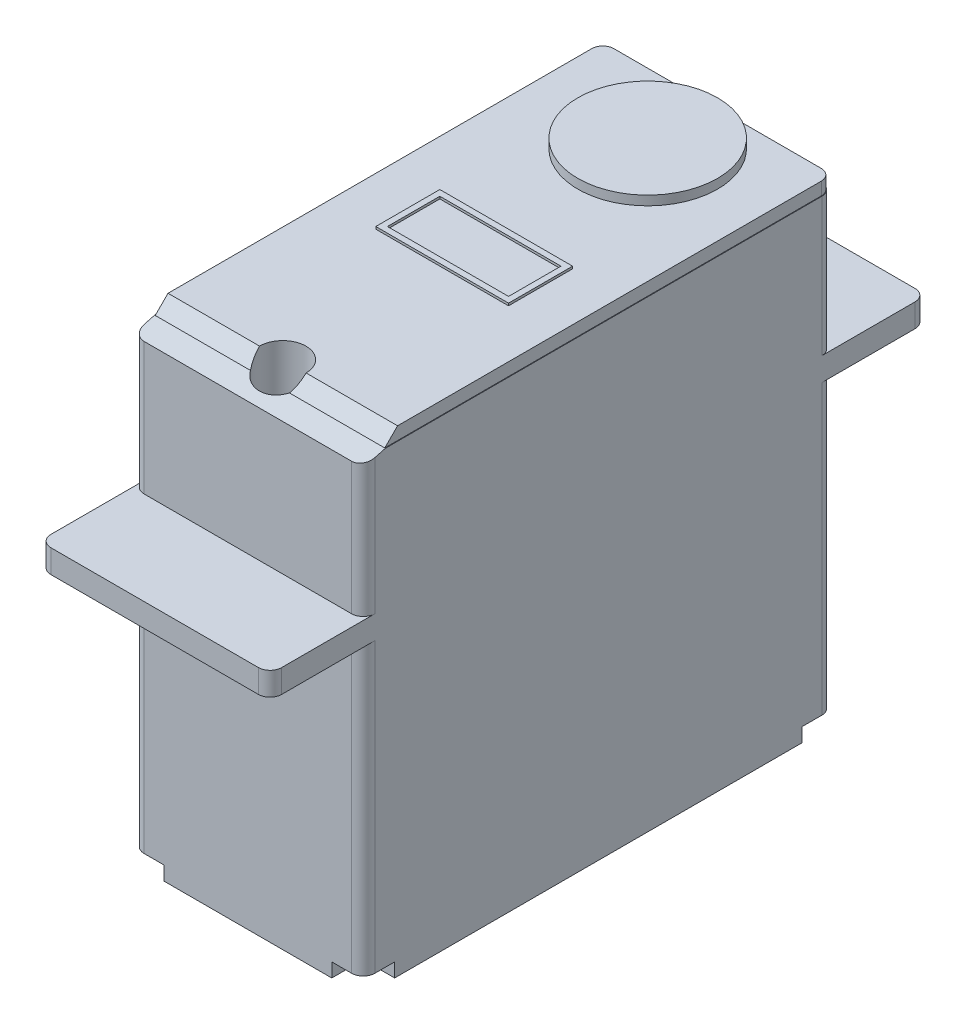
from build123d import *

# Parameters (mm, degrees)
ESQUISSE1_W                                   = 40.386
ESQUISSE1_H                                   = 40.894
BOSS_EXTRU_1_DEPTH                            = 9.906
ESQUISSE3_W                                   = 8.001
ESQUISSE3_H                                   = 2
BOSS_EXTRU_2_DEPTH                            = 19.812
ESQUISSE6_R                                   = 2
ENL_V_MAT_EXTRU_1_DEPTH                       = 13.954000064
ENL_V_MAT_EXTRU_1_DEPTH_BACK                  = 28.939999936
ESQUISSE5_R                                   = 6
BOSS_EXTRU_3_DEPTH                            = 0.8
CONG_2_R                                      = 1
ENL_V_MAT_EXTRU_2_DEPTH                       = 1.1
ENL_V_MAT_EXTRU_3_DEPTH                       = 1
ENL_V_MAT_EXTRU_3_DEPTH_BACK                  = 20.812
ESQUISSE9_W                                   = 11.4
ESQUISSE9_H                                   = 5.5
ESQUISSE9_W_2                                 = 10.4
ESQUISSE9_H_2                                 = 4.5
EXTRU_MINCE1_DEPTH                            = 0.2
ENL_V_MAT_EXTRU_4_DEPTH                       = 1
ENL_V_MAT_EXTRU_4_DEPTH_BACK                  = 1.2
TROU_POUR_TARAUDAGE_POUR_TROU_TARAUD_M1_D     = 0.95
TROU_POUR_TARAUDAGE_POUR_TROU_TARAUD_M1_DEPTH = 4.714591206
TROU_POUR_TARAUDAGE_POUR_TROU_TARAUD_M1_TIP   = 0.285408794
ESQUISSE16_W                                  = 3.6
ESQUISSE16_H                                  = 1.3
ENL_V_MAT_EXTRU_5_DEPTH                       = 5
ESQUISSE17_R                                  = 0.625
BOSS_EXTRU_5_DEPTH                            = 10
BOSS_EXTRU_5_2_DEPTH                          = 10
BOSS_EXTRU_5_3_DEPTH                          = 10


with BuildPart() as part:
    # Esquisse1 → Boss.-Extru.1 (new body, symmetric)
    with BuildSketch(Plane(origin=(0, 0, 0), x_dir=(0, 0, -1), z_dir=(1, 0, 0))):
        Rectangle(ESQUISSE1_W, ESQUISSE1_H)
    extrude(amount=BOSS_EXTRU_1_DEPTH, both=True)

    # Esquisse3 → Boss.-Extru.2 (add)
    with BuildSketch(Plane(origin=(9.906, 0, 0), x_dir=(0, 0, -1), z_dir=(1, 0, 0))):
        with Locations((-24.1935, 6.492999936)):
            Rectangle(ESQUISSE3_W, ESQUISSE3_H)
        with Locations((24.1935, 6.492999936)):
            Rectangle(ESQUISSE3_W, ESQUISSE3_H)
    extrude(amount=-BOSS_EXTRU_2_DEPTH)

    # Esquisse6 → Enlèv. mat.-Extru.1 (cut, two sides)
    with BuildSketch(Plane(origin=(0, 7.492999936, 0), x_dir=(1, 0, 0), z_dir=(0, 1, 0))) as enl_v_mat_extru_1_sk:
        with Locations((0, 17.2)):
            Circle(ESQUISSE6_R)
        with Locations((0, -17.2)):
            Circle(ESQUISSE6_R)
    extrude(amount=ENL_V_MAT_EXTRU_1_DEPTH, mode=Mode.SUBTRACT)
    extrude(enl_v_mat_extru_1_sk.sketch, amount=-ENL_V_MAT_EXTRU_1_DEPTH_BACK, mode=Mode.SUBTRACT)

    # Esquisse5 → Boss.-Extru.3 (add)
    with BuildSketch(Plane(origin=(0, 20.447, 0), x_dir=(1, 0, 0), z_dir=(0, 1, 0))):
        with Locations((0, 14.143)):
            Circle(ESQUISSE5_R)
    extrude(amount=BOSS_EXTRU_3_DEPTH)

    # Congé2
    cong_2_edges = [part.edges().sort_by_distance(p)[0] for p in [
        (9.906, -7.477000032, -20.193),
        (-9.906, 13.969999968, -20.193),
        (9.906, 13.969999968, -20.193),
        (-9.906, -7.477000032, 20.193),
        (9.906, -7.477000032, 20.193),
        (9.906, 6.492999936, 28.194),
        (-9.906, 6.492999936, 28.194),
        (9.906, 6.492999936, -28.194),
        (-9.906, 6.492999936, -28.194),
        (9.906, 13.969999968, 20.193),
        (-9.906, -7.477000032, -20.193),
        (-9.906, 13.969999968, 20.193),
    ]]
    fillet(cong_2_edges, radius=CONG_2_R)

    # Esquisse7 → Enlèv. mat.-Extru.2 (cut)
    with BuildSketch(Plane(origin=(0, 20.447, 0), x_dir=(1, 0, 0), z_dir=(0, 1, 0))):
        with BuildLine():
            Line((8.906, 20.193), (-8.906, 20.193))
            ThreePointArc((-8.906, 20.193), (-9.613106781, 19.900106781), (-9.906, 19.193))
            Line((-9.906, 19.193), (-9.906, -19.193))
            ThreePointArc((-9.906, -19.193), (-9.613106781, -19.900106781), (-8.906, -20.193))
            Line((-8.906, -20.193), (8.906, -20.193))
            ThreePointArc((8.906, -20.193), (9.613106781, -19.900106781), (9.906, -19.193))
            Line((9.906, -19.193), (9.906, 19.193))
            ThreePointArc((9.906, 19.193), (9.613106781, 19.900106781), (8.906, 20.193))
        make_face()
        with BuildLine():
            Line((8.906, 20.143), (-8.906, 20.143))
            ThreePointArc((-8.906, 20.143), (-9.577751442, 19.864751442), (-9.856, 19.193))
            Line((-9.856, 19.193), (-9.856, -19.193))
            ThreePointArc((-9.856, -19.193), (-9.577751442, -19.864751442), (-8.906, -20.143))
            Line((-8.906, -20.143), (8.906, -20.143))
            ThreePointArc((8.906, -20.143), (9.577751442, -19.864751442), (9.856, -19.193))
            Line((9.856, -19.193), (9.856, 19.193))
            ThreePointArc((9.856, 19.193), (9.577751442, 19.864751442), (8.906, 20.143))
        make_face(mode=Mode.SUBTRACT)
    extrude(amount=-ENL_V_MAT_EXTRU_2_DEPTH, mode=Mode.SUBTRACT)

    # Esquisse8 → Enlèv. mat.-Extru.3 (cut, two sides)
    with BuildSketch(Plane(origin=(9.906, 0, 0), x_dir=(0, 0, -1), z_dir=(1, 0, 0))) as enl_v_mat_extru_3_sk:
        Polygon((-17.193, 20.447), (-18.293, 19.347), (-20.193, 18.837896534), (-20.193, 20.447), align=None)
    extrude(amount=ENL_V_MAT_EXTRU_3_DEPTH, mode=Mode.SUBTRACT)
    extrude(enl_v_mat_extru_3_sk.sketch, amount=-ENL_V_MAT_EXTRU_3_DEPTH_BACK, mode=Mode.SUBTRACT)

    # Esquisse9 → Extru.-Mince1 (add)
    with BuildSketch(Plane(origin=(0, 20.447, 0), x_dir=(1, 0, 0), z_dir=(0, 1, 0))):
        with Locations((0, -0.757)):
            Rectangle(ESQUISSE9_W, ESQUISSE9_H)
        with Locations((0, -0.757)):
            Rectangle(ESQUISSE9_W_2, ESQUISSE9_H_2, mode=Mode.SUBTRACT)
    extrude(amount=EXTRU_MINCE1_DEPTH)

    # Esquisse13 → Enlèv. mat.-Extru.4 (cut, two sides)
    with BuildSketch(Plane.XZ.offset(20.447)) as enl_v_mat_extru_4_sk:
        with BuildLine():
            Line((-7.206, 20.193), (-9.906, 20.193))
            Line((-9.906, 20.193), (-9.906, 17.493))
            Line((-9.906, 17.493), (-8.706, 17.493))
            ThreePointArc((-8.706, 17.493), (-7.645339828, 17.932339828), (-7.206, 18.993))
            Line((-7.206, 18.993), (-7.206, 20.193))
        make_face()
        with BuildLine():
            Line((9.906, 20.193), (9.906, 17.493))
            Line((9.906, 17.493), (8.706, 17.493))
            ThreePointArc((8.706, 17.493), (7.645339828, 17.932339828), (7.206, 18.993))
            Line((7.206, 18.993), (7.206, 20.193))
            Line((7.206, 20.193), (9.906, 20.193))
        make_face()
        with BuildLine():
            Line((7.206, -20.193), (9.906, -20.193))
            Line((9.906, -20.193), (9.906, -17.493))
            Line((9.906, -17.493), (8.706, -17.493))
            ThreePointArc((8.706, -17.493), (7.645339828, -17.932339828), (7.206, -18.993))
            Line((7.206, -18.993), (7.206, -20.193))
        make_face()
        with BuildLine():
            Line((-9.906, -20.193), (-9.906, -17.493))
            Line((-9.906, -17.493), (-8.706, -17.493))
            ThreePointArc((-8.706, -17.493), (-7.645339828, -17.932339828), (-7.206, -18.993))
            Line((-7.206, -18.993), (-7.206, -20.193))
            Line((-7.206, -20.193), (-9.906, -20.193))
        make_face()
    extrude(amount=ENL_V_MAT_EXTRU_4_DEPTH, mode=Mode.SUBTRACT)
    extrude(enl_v_mat_extru_4_sk.sketch, amount=-ENL_V_MAT_EXTRU_4_DEPTH_BACK, mode=Mode.SUBTRACT)

    # Trou pour taraudage pour trou taraudé M1.2x0.251
    with Locations(Plane(origin=(0, -19.247, 0), x_dir=(-1, 0, 0), z_dir=(0, -1, 0))):
        with Locations((-8.706, -18.993), (8.906, -19.193), (-8.706, 18.993), (8.906, 19.193)):
            Hole(TROU_POUR_TARAUDAGE_POUR_TROU_TARAUD_M1_D / 2, depth=TROU_POUR_TARAUDAGE_POUR_TROU_TARAUD_M1_DEPTH)
            with Locations((0, 0, -(TROU_POUR_TARAUDAGE_POUR_TROU_TARAUD_M1_DEPTH + TROU_POUR_TARAUDAGE_POUR_TROU_TARAUD_M1_TIP / 2))):  # 118° drill point
                Cone(0, TROU_POUR_TARAUDAGE_POUR_TROU_TARAUD_M1_D / 2, TROU_POUR_TARAUDAGE_POUR_TROU_TARAUD_M1_TIP, mode=Mode.SUBTRACT)

    # Esquisse16 → Enlèv. mat.-Extru.5 (cut)
    with BuildSketch(Plane(origin=(0, 0, -20.193), x_dir=(-1, 0, 0), z_dir=(0, 0, -1))):
        with Locations((0, -15.697)):
            Rectangle(ESQUISSE16_W, ESQUISSE16_H)
    extrude(amount=-ENL_V_MAT_EXTRU_5_DEPTH, mode=Mode.SUBTRACT)


with BuildPart() as body_2:
    # Esquisse17 → Boss.-Extru.5 (new body)
    with BuildSketch(Plane(origin=(0, 0, -15.193), x_dir=(-1, 0, 0), z_dir=(0, 0, -1))):
        with Locations((0, -15.697)):
            Circle(ESQUISSE17_R)
    extrude(amount=BOSS_EXTRU_5_DEPTH)


with BuildPart() as body_3:
    # Esquisse17 → Boss.-Extru.5 2 (new body)
    with BuildSketch(Plane(origin=(0, 0, -15.193), x_dir=(-1, 0, 0), z_dir=(0, 0, -1))):
        with Locations((-1.25, -15.697)):
            Circle(ESQUISSE17_R)
    extrude(amount=BOSS_EXTRU_5_2_DEPTH)


with BuildPart() as body_4:
    # Esquisse17 → Boss.-Extru.5 3 (new body)
    with BuildSketch(Plane(origin=(0, 0, -15.193), x_dir=(-1, 0, 0), z_dir=(0, 0, -1))):
        with Locations((1.25, -15.697)):
            Circle(ESQUISSE17_R)
    extrude(amount=BOSS_EXTRU_5_3_DEPTH)


solid = Compound([part.part, body_2.part, body_3.part, body_4.part])
